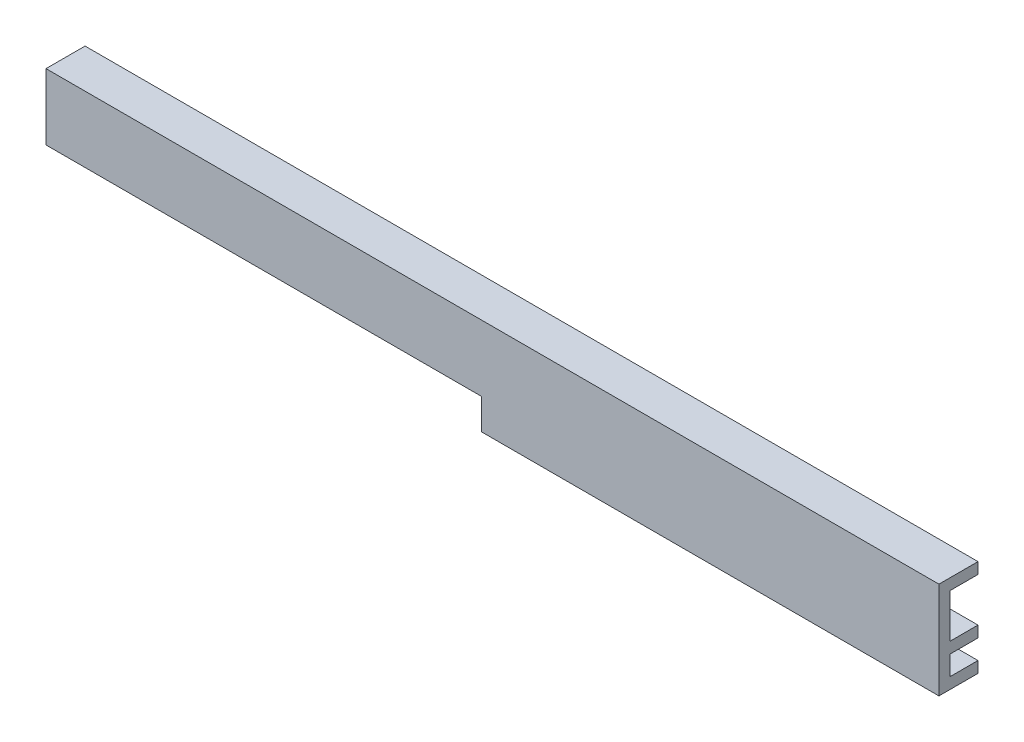
from build123d import *

# Parameters (mm, degrees)
ESBO_O1_W                = 160
ESBO_O1_H                = 2
ESBO_O1_W_2              = 80
RESSALTO_EXTRUS_O1_DEPTH = 5
ESBO_O1_3_W              = 160
ESBO_O1_3_H              = 7.85
ESBO_O1_3_W_2            = 80
ESBO_O1_3_H_2            = 3.5
ESBO_O1_3_H_3            = 2
RESSALTO_EXTRUS_O2_DEPTH = 2


with BuildPart() as part:
    # Esbo_o1 → Ressalto-extrus_o1 (new body)
    with BuildSketch(Plane.XY):
        with Locations((40.767792431, 15.391143911)):
            Rectangle(ESBO_O1_W, ESBO_O1_H)
        with Locations((40.767792431, 5.541143911)):
            Rectangle(ESBO_O1_W, ESBO_O1_H)
        with Locations((80.767792431, 0.041143911)):
            Rectangle(ESBO_O1_W_2, ESBO_O1_H)
        Polygon((40.767792431, 4.541143911), (38.767792431, 4.541143911), (38.767792431, -0.958856089), (40.767792431, -0.958856089), (40.767792431, 1.041143911), align=None)
    extrude(amount=-RESSALTO_EXTRUS_O1_DEPTH)

    # Esbo_o1_3 → Ressalto-extrus_o2 (add)
    with BuildSketch(Plane.XY):
        with Locations((40.767792431, 10.466143911)):
            Rectangle(ESBO_O1_3_W, ESBO_O1_3_H)
        with Locations((80.767792431, 2.791143911)):
            Rectangle(ESBO_O1_3_W_2, ESBO_O1_3_H_2)
        with Locations((40.767792431, 15.391143911)):
            Rectangle(ESBO_O1_3_W, ESBO_O1_3_H_3)
        with Locations((40.767792431, 5.541143911)):
            Rectangle(ESBO_O1_3_W, ESBO_O1_3_H_3)
        with Locations((80.767792431, 0.041143911)):
            Rectangle(ESBO_O1_3_W_2, ESBO_O1_3_H_3)
        Polygon((40.767792431, 4.541143911), (38.767792431, 4.541143911), (38.767792431, -0.958856089), (40.767792431, -0.958856089), (40.767792431, 1.041143911), align=None)
    extrude(amount=RESSALTO_EXTRUS_O2_DEPTH)


solid = part.part
